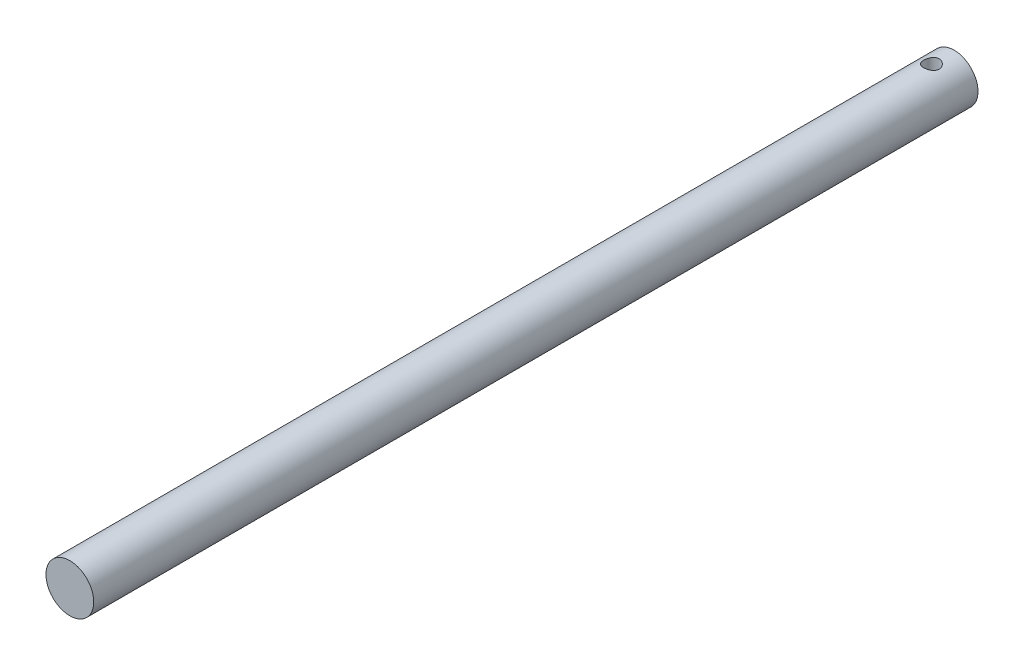
from build123d import *

# Parameters (mm, degrees)
SKETCH_1_R          = 10
EXTRUDE_1_DEPTH     = 370
SKETCH_2_R          = 3.25
CUT_EXTRUDE_1_DEPTH = 210


with BuildPart() as part:
    # 草图1 → 凸台-拉伸1 (new body)
    with BuildSketch(Plane.XY):
        Circle(SKETCH_1_R)
    extrude(amount=EXTRUDE_1_DEPTH)

    # 草图2 → 切除-拉伸1 (cut, symmetric)
    with BuildSketch(Plane(origin=(0, 0, 0), x_dir=(1, 0, 0), z_dir=(0, 1, 0))):
        with Locations((0, -9.5)):
            Circle(SKETCH_2_R)
    extrude(amount=CUT_EXTRUDE_1_DEPTH, both=True, mode=Mode.SUBTRACT)


solid = part.part
